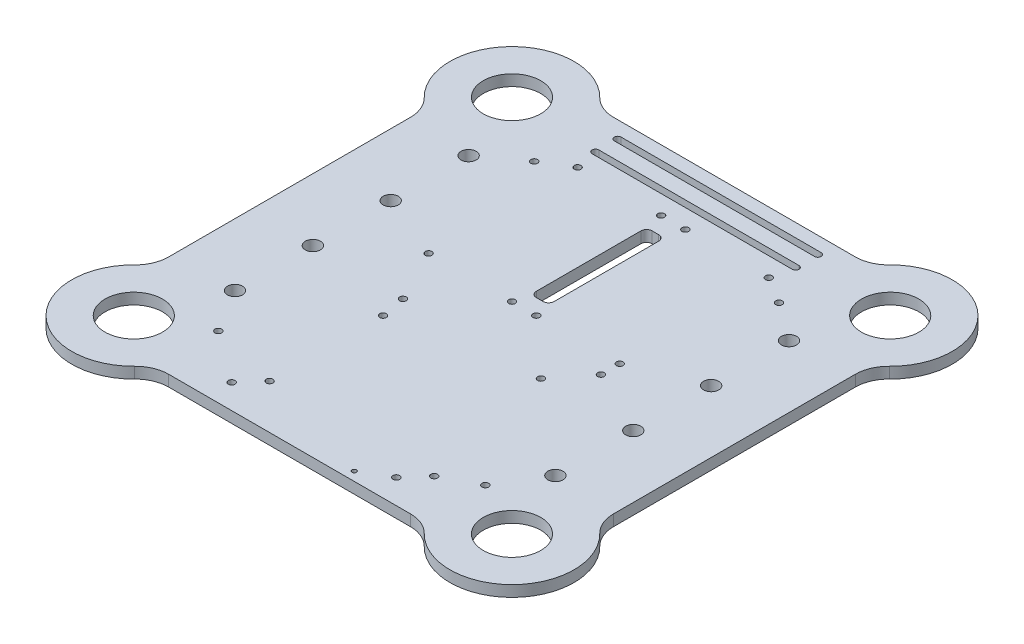
from build123d import *

# Parameters (mm, degrees)
SKETCH1_R          = 12.9
BASE_DEPTH         = 5
SKETCH2_R          = 1.5
SKETCH2_R_2        = 3.4
SKETCH2_R_3        = 1
CUT_EXTRUDE1_DEPTH = 6
CUT_EXTRUDE2_DEPTH = 6
SKETCH4_R          = 1.5
CUT_EXTRUDE3_DEPTH = 6


with BuildPart() as part:
    # Sketch1 → Base (new body)
    with BuildSketch(Plane(origin=(0, 0, 0), x_dir=(1, 0, 0), z_dir=(0, 1, 0))):
        with BuildLine():
            Line((0, 100), (54.333894933, 100))
            ThreePointArc((54.333894933, 100), (60.150136961, 101.173527975), (65.056309292, 104.51048951))
            ThreePointArc((65.056309292, 104.51048951), (104.728279195, 104.728279195), (104.51048951, 65.056309292))
            ThreePointArc((104.51048951, 65.056309292), (101.173527975, 60.150136961), (100, 54.333894933))
            Line((100, 54.333894933), (100, -54.333894933))
            ThreePointArc((100, -54.333894933), (101.173527975, -60.150136961), (104.51048951, -65.056309292))
            ThreePointArc((104.51048951, -65.056309292), (104.728279195, -104.728279195), (65.056309292, -104.51048951))
            ThreePointArc((65.056309292, -104.51048951), (60.150136961, -101.173527975), (54.333894933, -100))
            Line((54.333894933, -100), (0, -100))
            Line((0, -100), (0, 81))
            Line((0, 81), (45, 81))
            ThreePointArc((45, 81), (46.5, 82.5), (45, 84))
            Line((45, 84), (0, 84))
            Line((0, 84), (0, 91))
            Line((0, 91), (45, 91))
            ThreePointArc((45, 91), (46.5, 92.5), (45, 94))
            Line((45, 94), (0, 94))
            Line((0, 94), (0, 100))
        make_face()
        with Locations((85, 85)):
            Circle(SKETCH1_R, mode=Mode.SUBTRACT)
        with Locations((85, -85)):
            Circle(SKETCH1_R, mode=Mode.SUBTRACT)
    base = extrude(amount=BASE_DEPTH)

    # Mirror1: Base across plane
    add(base.mirror(Plane(origin=(0, 0, 0), x_dir=(0, 0, 1), z_dir=(1, 0, 0))))

    # Sketch2 → Cut-Extrude1 (cut, through all)
    with BuildSketch(Plane(origin=(0, 5, 0), x_dir=(1, 0, 0), z_dir=(0, 1, 0))):
        with Locations((-42.960009902, 72.46)):
            Circle(SKETCH2_R)
        with Locations((-5.460009902, 72.46)):
            Circle(SKETCH2_R)
        with Locations((5.460009902, 72.46)):
            Circle(SKETCH2_R)
        with Locations((42.960009902, 72.46)):
            Circle(SKETCH2_R)
        with Locations((72.009618943, 52.5)):
            Circle(SKETCH2_R_2)
        with Locations((-28.986150524, -79.986157497)):
            Circle(SKETCH2_R)
        with Locations((72.009618943, -17.5)):
            Circle(SKETCH2_R_2)
        with Locations((72.009618943, -52.5)):
            Circle(SKETCH2_R_2)
        with Locations((42.960009902, 5.46)):
            Circle(SKETCH2_R)
        with Locations((42.960009902, -2.986157497)):
            Circle(SKETCH2_R)
        with Locations((5.460009902, 5.46)):
            Circle(SKETCH2_R)
        with Locations((-5.460009902, 5.46)):
            Circle(SKETCH2_R)
        with Locations((-28.986150524, -28.986157497)):
            Circle(SKETCH2_R)
        with Locations((-42.960009902, 5.46)):
            Circle(SKETCH2_R)
        with Locations((-72.009618943, 52.5)):
            Circle(SKETCH2_R_2)
        with Locations((-72.009618943, -17.5)):
            Circle(SKETCH2_R_2)
        with Locations((-72.009618943, -52.5)):
            Circle(SKETCH2_R_2)
        with Locations((45.013849476, -79.986157497)):
            Circle(SKETCH2_R)
        with Locations((36.999763655, -89)):
            Circle(SKETCH2_R)
        with Locations((-37.000236345, -89)):
            Circle(SKETCH2_R)
        with Locations((-72.009618943, 17.5)):
            Circle(SKETCH2_R_2)
        with Locations((72.009618943, 17.5)):
            Circle(SKETCH2_R_2)
        with Locations((25.1, -96)):
            Circle(SKETCH2_R_3)
    extrude(amount=-CUT_EXTRUDE1_DEPTH, mode=Mode.SUBTRACT)

    # Sketch3 → Cut-Extrude2 (cut, through all)
    with BuildSketch(Plane(origin=(0, 5, 0), x_dir=(1, 0, 0), z_dir=(0, 1, 0))):
        with BuildLine():
            Line((0, 64.46), (1.5, 64.46))
            ThreePointArc((1.5, 64.46), (3.267766953, 63.727766953), (4, 61.96))
            Line((4, 61.96), (4, 14.96))
            ThreePointArc((4, 14.96), (3.267766953, 13.192233047), (1.5, 12.46))
            Line((1.5, 12.46), (-1.5, 12.46))
            ThreePointArc((-1.5, 12.46), (-3.267766953, 13.192233047), (-4, 14.96))
            Line((-4, 14.96), (-4, 61.96))
            ThreePointArc((-4, 61.96), (-3.267766953, 63.727766953), (-1.5, 64.46))
            Line((-1.5, 64.46), (0, 64.46))
        make_face()
    extrude(amount=-CUT_EXTRUDE2_DEPTH, mode=Mode.SUBTRACT)

    # Sketch4 → Cut-Extrude3 (cut, through all)
    with BuildSketch(Plane(origin=(0, 5, 0), x_dir=(1, 0, 0), z_dir=(0, 1, 0))):
        with Locations((-55.009618943, 65)):
            Circle(SKETCH4_R)
        with Locations((55.009618943, 65)):
            Circle(SKETCH4_R)
        with Locations((-60.009618943, -72)):
            Circle(SKETCH4_R)
        with Locations((60.009618943, -72)):
            Circle(SKETCH4_R)
        with Locations((31.009618943, -18)):
            Circle(SKETCH4_R)
        with Locations((-31.009618943, -18)):
            Circle(SKETCH4_R)
    extrude(amount=-CUT_EXTRUDE3_DEPTH, mode=Mode.SUBTRACT)


solid = part.part
